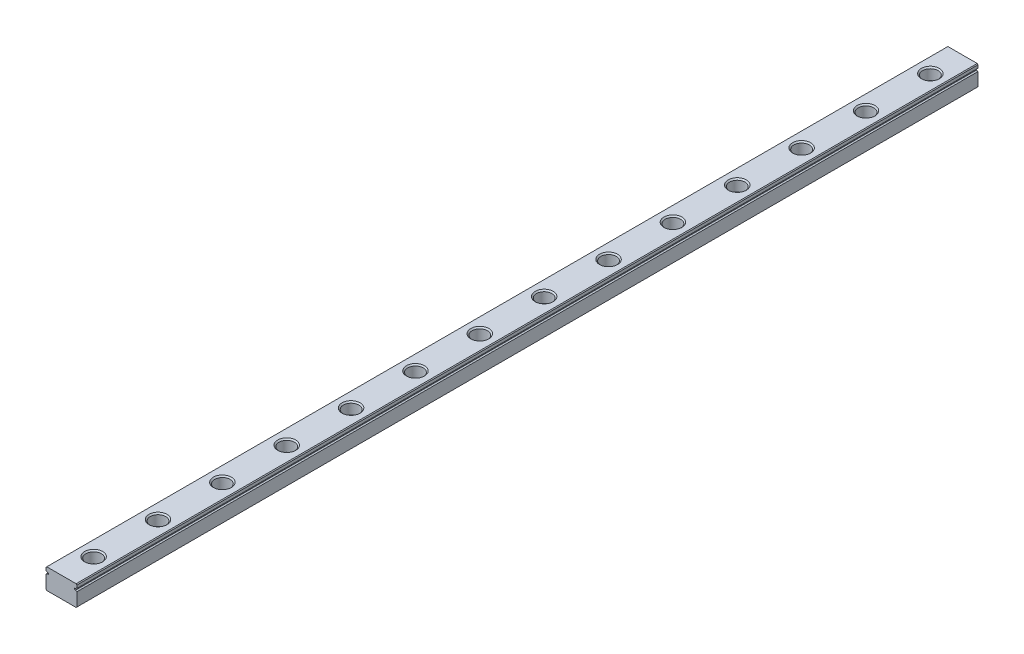
from build123d import *

# Parameters (mm, degrees)
BOSS_EXTRUDE1_DEPTH = 350
CHAMFER1_SIZE       = 0.3
LPATTERN1_COUNT     = 14
LPATTERN1_PITCH     = 25


with BuildPart() as part:
    # Sketch1 → Boss-Extrude1 (new body)
    with BuildSketch(Plane.XY):
        with BuildLine():
            Line((-6, 4), (6, 4))
            Line((6, 4), (6, 2.75))
            Line((6, 2.75), (6, 2.559016994))
            ThreePointArc((6, 2.559016994), (5.706107374, 2.475528258), (5.5, 2.25))
            Line((5.5, 2.25), (5, 2.25))
            Line((5, 2.25), (5, 1.75))
            Line((5, 1.75), (5.5, 1.75))
            ThreePointArc((5.5, 1.75), (5.706107374, 1.524471742), (6, 1.440983006))
            Line((6, 1.440983006), (6, 1.25))
            Line((6, 1.25), (6, -4))
            Line((6, -4), (-6, -4))
            Line((-6, -4), (-6, 1.25))
            Line((-6, 1.25), (-6, 1.440983006))
            ThreePointArc((-6, 1.440983006), (-5.706107374, 1.524471742), (-5.5, 1.75))
            Line((-5.5, 1.75), (-5, 1.75))
            Line((-5, 1.75), (-5, 2.25))
            Line((-5, 2.25), (-5.5, 2.25))
            ThreePointArc((-5.5, 2.25), (-5.706107374, 2.475528258), (-6, 2.559016994))
            Line((-6, 2.559016994), (-6, 2.75))
            Line((-6, 2.75), (-6, 4))
        make_face()
    extrude(amount=BOSS_EXTRUDE1_DEPTH)

    # Chamfer1
    chamfer1_edges = [part.edges().sort_by_distance(p)[0] for p in [
        (-6, 4, 175),
        (6, 4, 175),
        (6, -4, 175),
        (-6, -4, 175),
    ]]
    chamfer(chamfer1_edges, length=CHAMFER1_SIZE)

    # Sketch3 → M3 六角承窩頭蓋螺釘的柱孔1 (revolve, cut)
    with BuildSketch(Plane(origin=(0, 4, 12.5), x_dir=(0, 0, 1), z_dir=(1, 0, 0))):
        Polygon((0, 0), (0, 8), (2, 8), (1.75, 7.75), (1.75, 4.5), (3, 4.5), (3, 0.5), (3.5, 0), align=None)
    hole_wizard_m3_1 = revolve(axis=Axis((0, 10.35, 12.5), (0, -1, 0)), mode=Mode.SUBTRACT)

    # LPattern1: M3 六角承窩頭蓋螺釘的柱孔1 ×14
    with Locations(*[(0, 0, i * LPATTERN1_PITCH) for i in range(1, LPATTERN1_COUNT)]):
        add(hole_wizard_m3_1, mode=Mode.SUBTRACT)


solid = part.part
